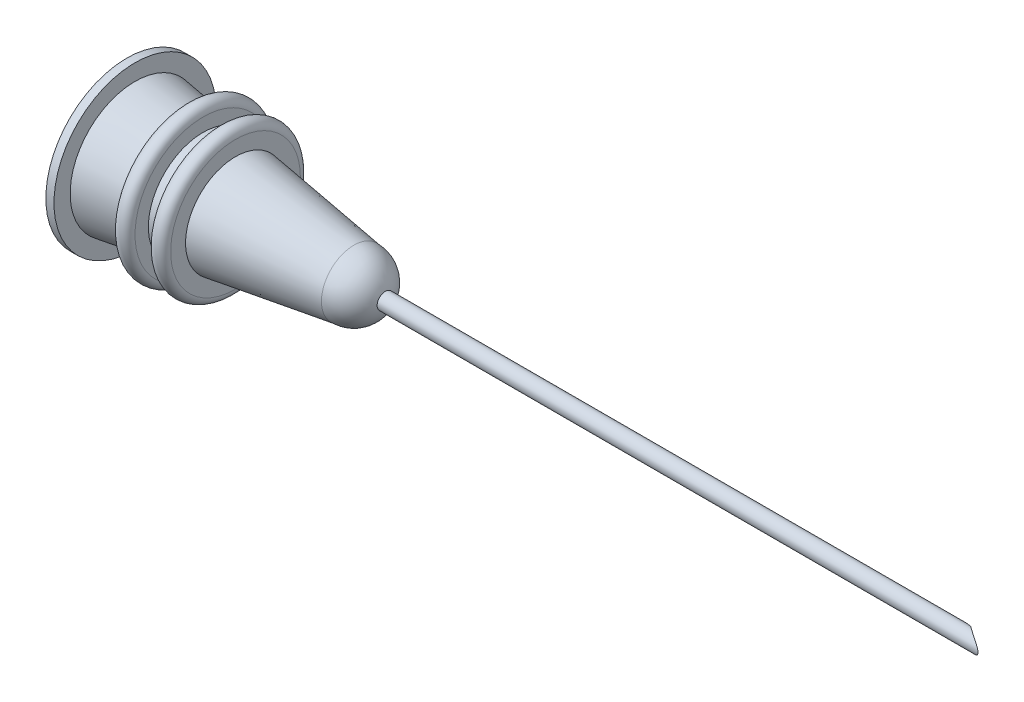
from build123d import *

# Parameters (mm, degrees)
DOME1_FACE_RADIUS       = 2
DOME1_HEIGHT            = 2
SKETCH2_R               = 0.5
CUT_EXTRUDE1_DEPTH      = 4
SKETCH3_R               = 0.5
SKETCH3_R_2             = 0.375
EXTRUDE_THIN1_DEPTH     = 40
SKETCH4_R               = 3.5
CUT_EXTRUDE2_DEPTH      = 6
CUT_EXTRUDE2_DEPTH_BACK = 6
SKETCH6_R               = 5
CUT_EXTRUDE3_DEPTH      = 6
CUT_EXTRUDE3_DEPTH_BACK = 6


with BuildPart() as part:
    # Sketch1 → Revolve1 (revolve)
    with BuildSketch(Plane.XY):
        with BuildLine():
            Line((0, 0), (0, 2))
            Line((0, 2), (-7.3, 3.081481481))
            Line((-7.3, 3.081481481), (-7.3, 4))
            ThreePointArc((-7.3, 4), (-7.8, 4.5), (-8.3, 4))
            Line((-8.3, 4), (-8.3, 3.22962963))
            Line((-8.3, 3.22962963), (-9.3, 3.377777778))
            Line((-9.3, 3.377777778), (-9.3, 4.2))
            ThreePointArc((-9.3, 4.2), (-9.8, 4.7), (-10.3, 4.2))
            Line((-10.3, 4.2), (-10.3, 3.525925926))
            Line((-10.3, 3.525925926), (-13.5, 4))
            Line((-13.5, 4), (-13.5, 5))
            Line((-13.5, 5), (-14, 5))
            Line((-14, 5), (-14, 3.315888293))
            Line((-14, 3.315888293), (-1, 1.389962367))
            Line((-1, 1.389962367), (-1, 0))
            Line((-1, 0), (0, 0))
        make_face()
    revolve(axis=Axis((0, 0, 0), (-1, 0, 0)))

    # Dome1: a dome of height H over a round flat face of radius A is a cap of a sphere of radius (A * A + H * H) / (2 * H)
    dome1_r = (DOME1_FACE_RADIUS * DOME1_FACE_RADIUS + DOME1_HEIGHT * DOME1_HEIGHT) / (2 * DOME1_HEIGHT)
    dome1_base = Plane((0, 0, 0), z_dir=(1, 0, 0))
    with Locations(dome1_base.offset(DOME1_HEIGHT - dome1_r)):
        dome1_ball = Sphere(dome1_r, mode=Mode.PRIVATE)
    add(split(dome1_ball, bisect_by=dome1_base, keep=Keep.TOP, mode=Mode.PRIVATE))

    # Sketch2 → Cut-Extrude1 (cut, through all)
    with BuildSketch(Plane.ZY.offset(1)):
        Circle(SKETCH2_R)
    extrude(amount=-CUT_EXTRUDE1_DEPTH, mode=Mode.SUBTRACT)

    # Sketch3 → Extrude-Thin1 (add)
    with BuildSketch(Plane.ZY.offset(1)):
        Circle(SKETCH3_R)
        Circle(SKETCH3_R_2, mode=Mode.SUBTRACT)
    extrude(amount=-EXTRUDE_THIN1_DEPTH)

    # Sketch4 → Cut-Extrude2 (cut, two sides)
    with BuildSketch(Plane(origin=(0, 0, 0), x_dir=(1, 0, 0), z_dir=(0, 1, 0))) as cut_extrude2_sk:
        with Locations((39, 3.5)):
            Circle(SKETCH4_R)
    extrude(amount=CUT_EXTRUDE2_DEPTH, mode=Mode.SUBTRACT)
    extrude(cut_extrude2_sk.sketch, amount=-CUT_EXTRUDE2_DEPTH_BACK, mode=Mode.SUBTRACT)

    # Sketch6 → Cut-Extrude3 (cut, two sides)
    with BuildSketch(Plane(origin=(0, 0, 0), x_dir=(1, 0, 0), z_dir=(0, 1, 0))) as cut_extrude3_sk:
        with Locations((41, 4.082575695)):
            Circle(SKETCH6_R)
    extrude(amount=CUT_EXTRUDE3_DEPTH, mode=Mode.SUBTRACT)
    extrude(cut_extrude3_sk.sketch, amount=-CUT_EXTRUDE3_DEPTH_BACK, mode=Mode.SUBTRACT)


solid = part.part
